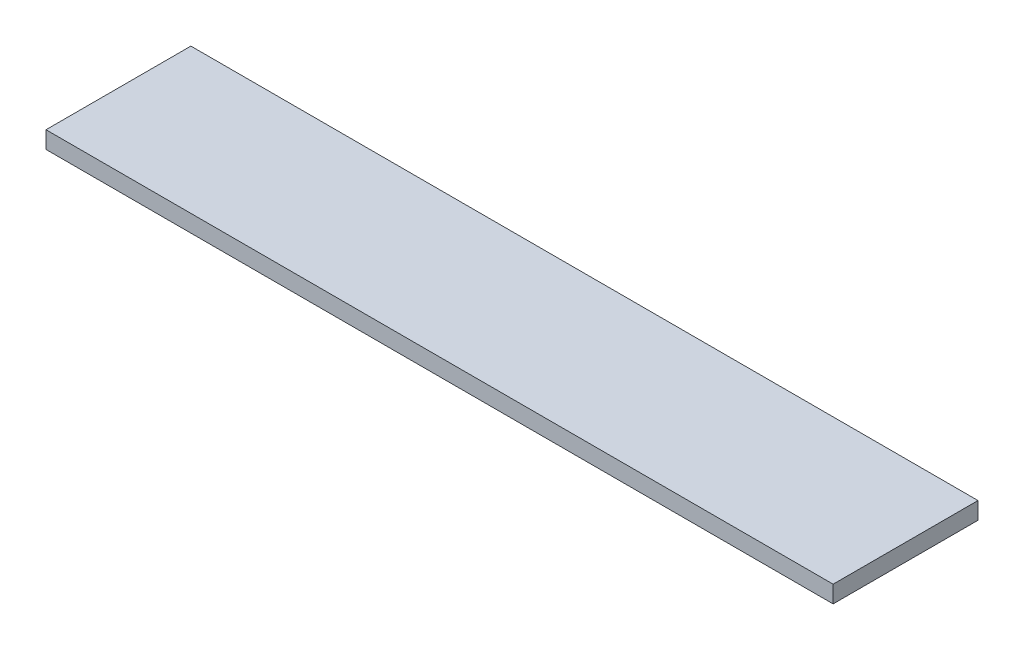
from build123d import *

# Parameters (mm, degrees)
SKETCH1_W           = 138
SKETCH1_H           = 25.4
BOSS_EXTRUDE1_DEPTH = 3


with BuildPart() as part:
    # Sketch1 → Boss-Extrude1 (new body)
    with BuildSketch(Plane(origin=(0, 0, 0), x_dir=(1, 0, 0), z_dir=(0, 1, 0))):
        with Locations((13.798822058, 6.362355235)):
            Rectangle(SKETCH1_W, SKETCH1_H)
    extrude(amount=BOSS_EXTRUDE1_DEPTH)


solid = part.part
